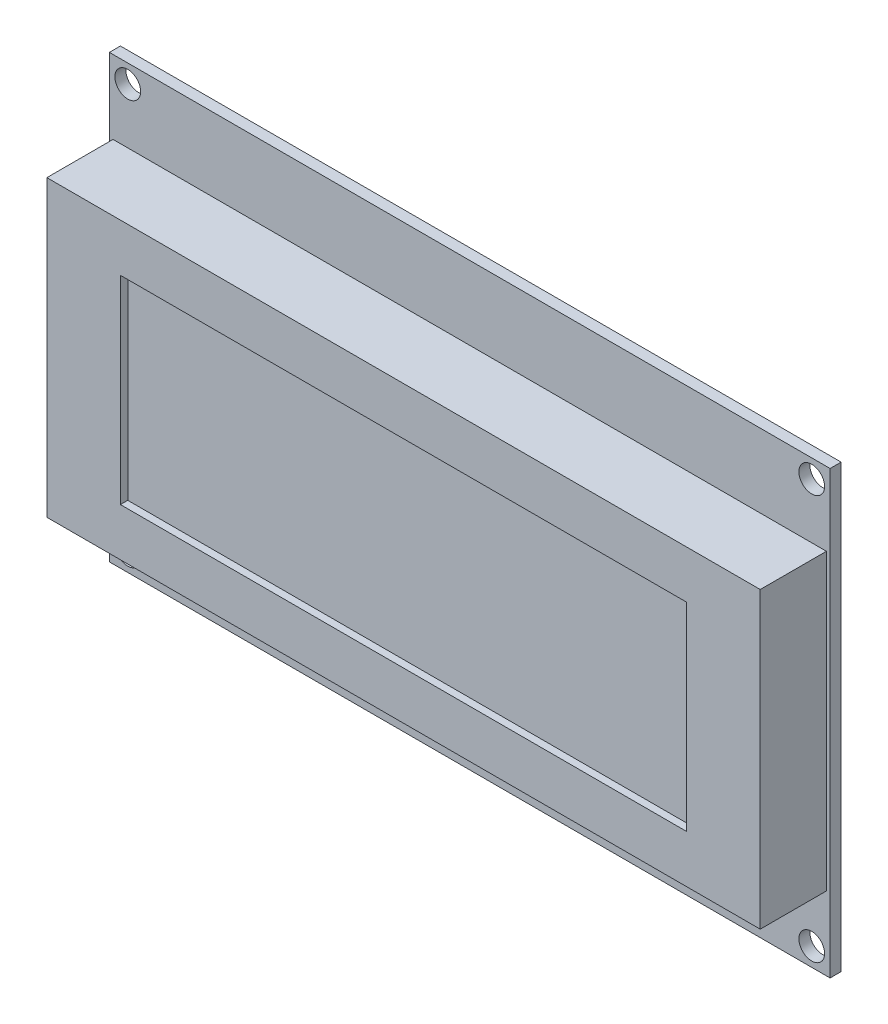
from build123d import *

# Parameters (mm, degrees)
SKETCH1_W           = 98
SKETCH1_H           = 60
BOSS_EXTRUDE1_DEPTH = 1.5
SKETCH2_W           = 98
SKETCH2_H           = 40
BOSS_EXTRUDE2_DEPTH = 9
SKETCH3_W           = 77
SKETCH3_H           = 27
CUT_EXTRUDE1_DEPTH  = 1
SKETCH4_R           = 1.75
CUT_EXTRUDE2_DEPTH  = 2.5
SKETCH5_W           = 42
SKETCH5_H           = 20
BOSS_EXTRUDE3_DEPTH = 9
SKETCH6_W           = 18.449888981
SKETCH6_H           = 44.735350261
SKETCH6_W_2         = 5.736894001
SKETCH6_H_2         = 46.054623325
CUT_EXTRUDE3_DEPTH  = 9


with BuildPart() as part:
    # Sketch1 → Boss-Extrude1 (new body)
    with BuildSketch(Plane.XY):
        Rectangle(SKETCH1_W, SKETCH1_H)
    extrude(amount=BOSS_EXTRUDE1_DEPTH)

    # Sketch2 → Boss-Extrude2 (add)
    with BuildSketch(Plane.XY.offset(1.5)):
        Rectangle(SKETCH2_W, SKETCH2_H)
    extrude(amount=BOSS_EXTRUDE2_DEPTH)

    # Sketch3 → Cut-Extrude1 (cut)
    with BuildSketch(Plane.XY.offset(10.5)):
        Rectangle(SKETCH3_W, SKETCH3_H)
    extrude(amount=-CUT_EXTRUDE1_DEPTH, mode=Mode.SUBTRACT)

    # Sketch4 → Cut-Extrude2 (cut, through all)
    with BuildSketch(Plane.XY.offset(1.5)):
        with Locations((-46.5, 27.5)):
            Circle(SKETCH4_R)
        with Locations((46.5, 27.5)):
            Circle(SKETCH4_R)
        with Locations((46.5, -27.5)):
            Circle(SKETCH4_R)
        with Locations((-46.5, -27.5)):
            Circle(SKETCH4_R)
    extrude(amount=-CUT_EXTRUDE2_DEPTH, mode=Mode.SUBTRACT)

    # Sketch5 → Boss-Extrude3 (add)
    with BuildSketch(Plane(origin=(0, 0, 0), x_dir=(-1, 0, 0), z_dir=(0, 0, -1))):
        with Locations((-19, -18)):
            Rectangle(SKETCH5_W, SKETCH5_H)
    extrude(amount=BOSS_EXTRUDE3_DEPTH)

    # Sketch6 → Cut-Extrude3 (cut)
    with BuildSketch(Plane.XY.offset(10.5)):
        with Locations((-57.724944491, 0.8097006)):
            Rectangle(SKETCH6_W, SKETCH6_H)
        with Locations((51.368447, 0.150064069)):
            Rectangle(SKETCH6_W_2, SKETCH6_H_2)
    extrude(amount=-CUT_EXTRUDE3_DEPTH, mode=Mode.SUBTRACT)


solid = part.part
